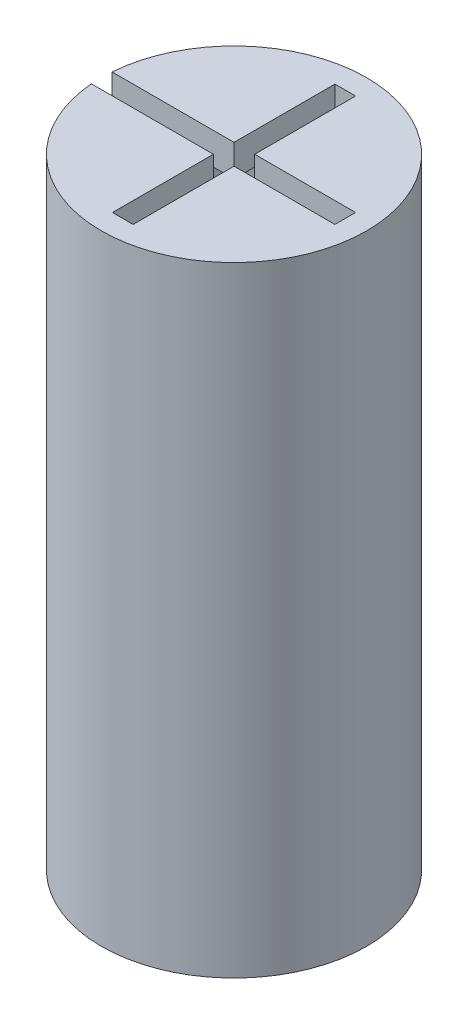
from build123d import *

# Parameters (mm, degrees)
CUT_EXTRUDE1_DEPTH      = 1
CUT_EXTRUDE1_DEPTH_BACK = 40


with BuildPart() as part:
    # Sketch1 → Revolve1 (revolve)
    with BuildSketch(Plane.XY):
        Polygon((-6.35, 0), (-8.35, 0), (-8.35, 39), (0, 39), (0, 37), (-4.35, 37), (-4.35, 21), (-6.35, 21), align=None)
    revolve(axis=Axis((0, 0, 0), (0, 1, 0)))

    # Sketch2 → Cut-Extrude1 (cut, two sides)
    with BuildSketch(Plane(origin=(0, 39, 0), x_dir=(1, 0, 0), z_dir=(0, 1, 0))) as cut_extrude1_sk:
        Polygon((-0.65, 0.65), (-7, 0.65), (-11.662246707, 0.65), (-11.662246707, -0.65), (-7, -0.65), (-0.65, -0.65), (-0.65, -7), (0.65, -7), (0.65, -0.65), (7, -0.65), (7, 0.65), (0.65, 0.65), (0.65, 7), (-0.65, 7), align=None)
    extrude(amount=CUT_EXTRUDE1_DEPTH, mode=Mode.SUBTRACT)
    extrude(cut_extrude1_sk.sketch, amount=-CUT_EXTRUDE1_DEPTH_BACK, mode=Mode.SUBTRACT)


solid = part.part
